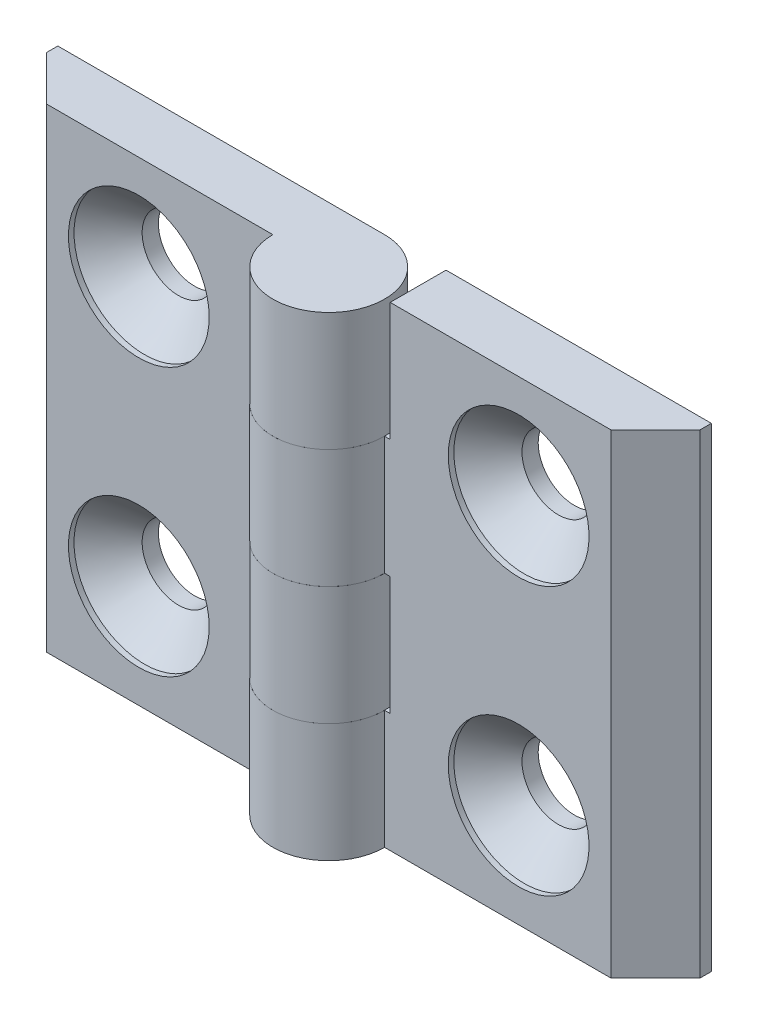
from build123d import *

# Parameters (mm, degrees)
EXTRUDE_1_DEPTH            = 21.25
SKETCH_3_W                 = 10.5
SKETCH_3_H                 = 10.625
CUT_EXTRUDE_1_DEPTH        = 6
CUT_EXTRUDE_1_DEPTH_BACK   = 6
HOLE_WIZARD_M61_AT_2_COUNT = 2
HOLE_WIZARD_M61_AT_2_PITCH = 24
PATTERN_CIRCULAR_1_COUNT   = 2


with BuildPart() as part:
    # Эскиз1 → Бобышка-Вытянуть1 (new body, symmetric)
    with BuildSketch(Plane(origin=(0, 0, 0), x_dir=(1, 0, 0), z_dir=(0, 1, 0))):
        with BuildLine():
            Line((0, 5), (-29.25, 5))
            Line((-29.25, 5), (-29.25, 4))
            Line((-29.25, 4), (-25.25, 0))
            Line((-25.25, 0), (-5, 0))
            ThreePointArc((-5, 0), (3.535533906, -3.535533906), (0, 5))
        make_face()
    extrude(amount=EXTRUDE_1_DEPTH, both=True)

    # Эскиз3 → Вырез-Вытянуть1 (cut, two sides)
    with BuildSketch(Plane.XY) as cut_extrude_1_sk:
        with Locations((-0.25, 5.3125)):
            Rectangle(SKETCH_3_W, SKETCH_3_H)
        with Locations((-0.25, -15.9375)):
            Rectangle(SKETCH_3_W, SKETCH_3_H)
    extrude(amount=CUT_EXTRUDE_1_DEPTH, mode=Mode.SUBTRACT)
    extrude(cut_extrude_1_sk.sketch, amount=-CUT_EXTRUDE_1_DEPTH_BACK, mode=Mode.SUBTRACT)

    # Эскиз6 → Зенковка для винта с полупотайной головкой M61 (revolve, cut)
    with BuildSketch(Plane(origin=(-17, 12, 0), x_dir=(0, -1, 0), z_dir=(1, 0, 0))):
        Polygon((0, 0), (0, 5), (3.25, 5), (3.25, 3.55), (6.3, 0.5), (6.3, 0), align=None)
    hole_wizard_m61 = revolve(axis=Axis((-17, 12, 6.35), (0, 0, -1)), mode=Mode.SUBTRACT)

    # Зенковка для винта с полупотайной головкой M61 at 2: Зенковка для винта с полупотайной головкой M61 ×2
    with Locations(*[(0, -i * HOLE_WIZARD_M61_AT_2_PITCH, 0) for i in range(1, HOLE_WIZARD_M61_AT_2_COUNT)]):
        add(hole_wizard_m61, mode=Mode.SUBTRACT)


with BuildPart() as pattern_circular_1_1:
    # Круговой массив1: pattern copy
    add(part.part.rotate(Axis((0, 0, 0), (0, 0, 1)), 1 * 360 / PATTERN_CIRCULAR_1_COUNT))


solid = Compound([part.part, pattern_circular_1_1.part])
